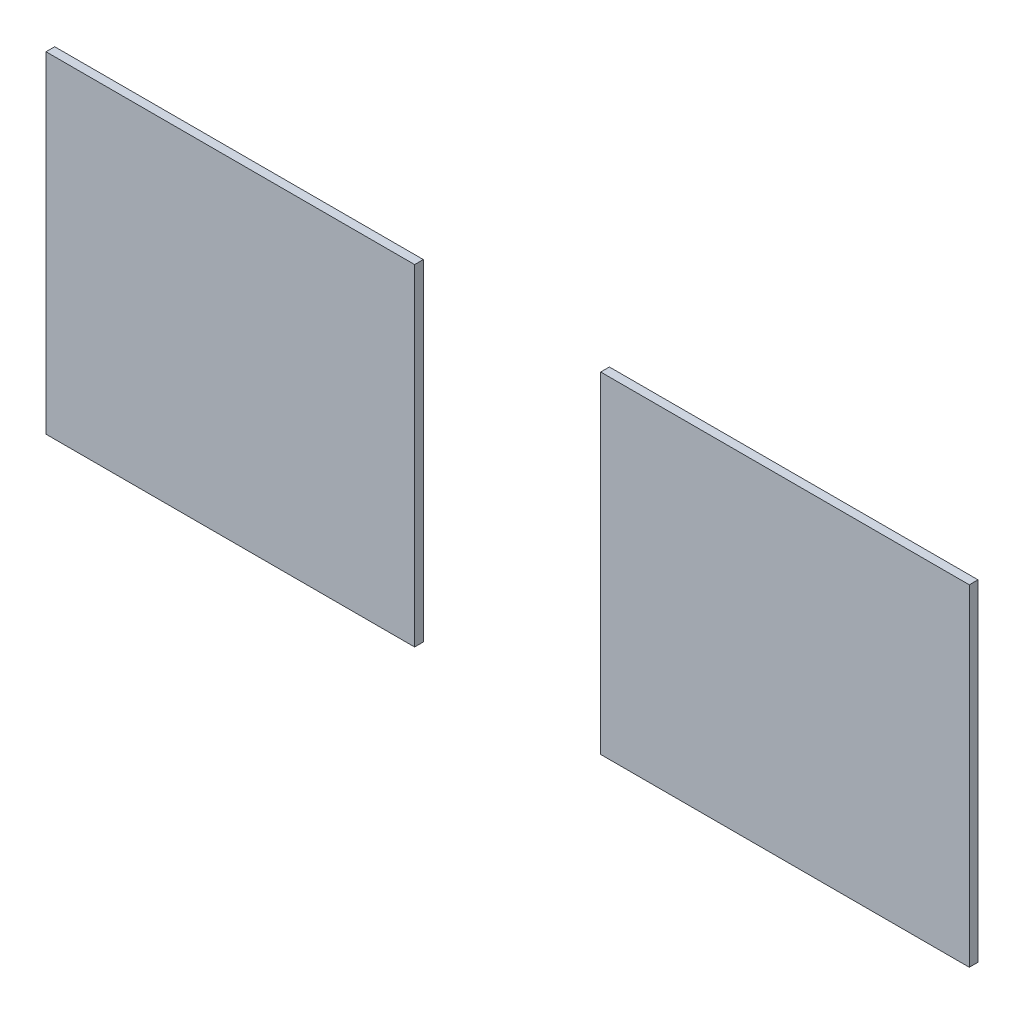
from build123d import *

# Parameters (mm, degrees)
ESQUISSE2_W          = 4.24
ESQUISSE2_H          = 3.81
BOSS_EXTRU_1_DEPTH   = 0.1
BOSS_EXTRU_1_2_DEPTH = 0.1


with BuildPart() as part:
    # Esquisse2 → Boss.-Extru.1 (new body)
    with BuildSketch(Plane.XY):
        with Locations((2.12, 1.905)):
            Rectangle(ESQUISSE2_W, ESQUISSE2_H)
    extrude(amount=BOSS_EXTRU_1_DEPTH)


with BuildPart() as body_2:
    # Esquisse2 → Boss.-Extru.1 2 (new body)
    with BuildSketch(Plane.XY):
        with Locations((8.5, 1.905)):
            Rectangle(ESQUISSE2_W, ESQUISSE2_H)
    extrude(amount=BOSS_EXTRU_1_2_DEPTH)


solid = Compound([part.part, body_2.part])
